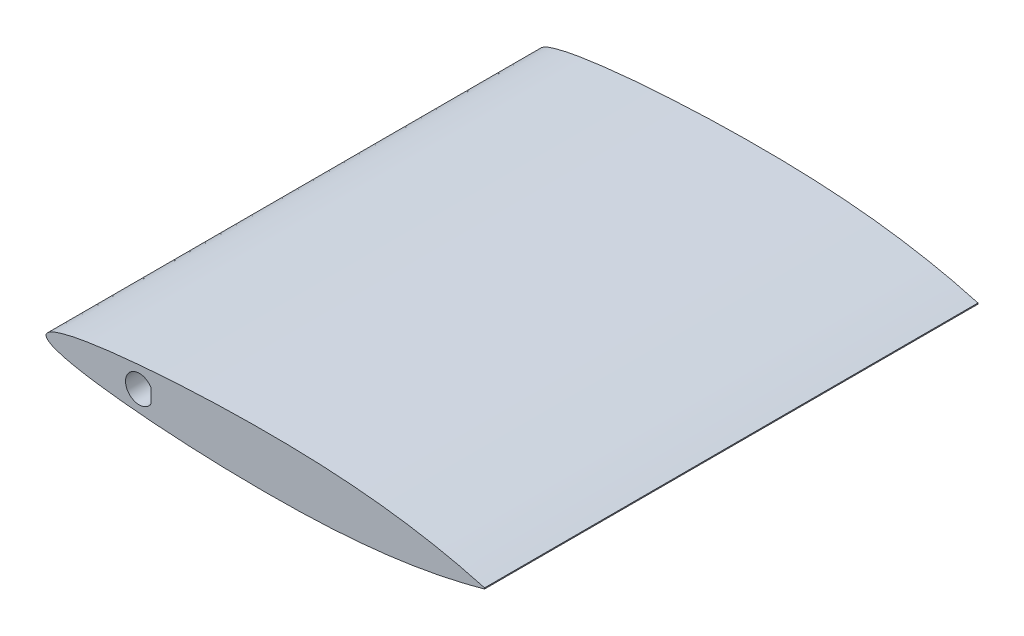
from build123d import *

# Parameters (mm, degrees)
BOSS_EXTRUDE1_DEPTH = 114.3
CUT_EXTRUDE1_DEPTH  = 115.3000001


with BuildPart() as part:
    # Sketch1 → Boss-Extrude1 (new body)
    with BuildSketch(Plane.XY):
        with BuildLine():
            Line((101.6, 0.12192), (101.6, -0.12192))
            add(Edge.make_bspline(
                [(101.6, 0.12192), (99.909932561, 0.573751352), (96.544515968, 1.473479194), (89.783814833, 2.947081601), (81.321913594, 4.36676175), (71.140279871, 5.436356516), (60.967102616, 5.996645411), (50.800006263, 6.145246679), (40.635675917, 5.998253513), (30.470830523, 5.552954054), (22.003048387, 4.932932422), (15.230811891, 4.223162727), (10.998681463, 3.664214628), (7.608030333, 3.092241666), (5.072149413, 2.580804534), (2.89436287, 1.970888591), (1.181665174, 1.364209186), (-0.674617494, 0), (1.181665174, -1.364209186), (2.89436287, -1.970888591), (5.072149413, -2.580804534), (7.608030333, -3.092241666), (10.998681463, -3.664214628), (15.230811891, -4.223162727), (22.003048387, -4.932932422), (30.470830523, -5.552954054), (40.635675917, -5.998253513), (50.800006263, -6.145246679), (60.967102616, -5.996645411), (71.140279871, -5.436356516), (81.321913594, -4.36676175), (89.783814833, -2.947081601), (96.544515968, -1.473479194), (99.909932561, -0.573751352), (101.6, -0.12192)],
                knots=[0, 0, 0, 0, 0.025456141, 0.050690592, 0.100668945, 0.150236314, 0.199601231, 0.248893973, 0.298185188, 0.347518476, 0.39694404, 0.421724596, 0.446593141, 0.459091427, 0.471679672, 0.4844804, 0.491139797, 0.5, 0.508860203, 0.5155196, 0.528320328, 0.540908573, 0.553406859, 0.578275404, 0.60305596, 0.652481524, 0.701814812, 0.751106027, 0.800398769, 0.849763686, 0.899331055, 0.949309408, 0.974543859, 1, 1, 1, 1], degree=3))
        make_face()
    extrude(amount=BOSS_EXTRUDE1_DEPTH)

    # Sketch2 → Cut-Extrude1 (cut, through all)
    with BuildSketch(Plane.XY.offset(114.3)):
        with BuildLine():
            Line((24.349630657, 1.5875), (24.349630657, -1.5875))
            ThreePointArc((24.349630657, -1.5875), (18.425, 0), (24.349630657, 1.5875))
        make_face()
    extrude(amount=-CUT_EXTRUDE1_DEPTH, mode=Mode.SUBTRACT)


solid = part.part
